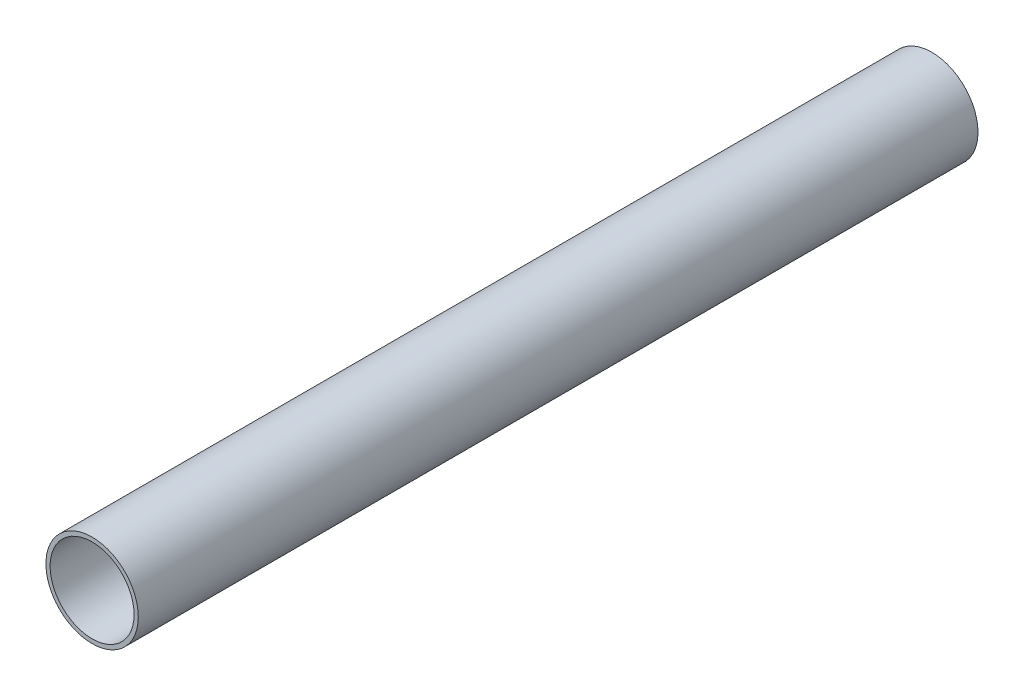
from build123d import *

# Parameters (mm, degrees)
ESQUISSE1_R      = 1.65
ESQUISSE1_R_2    = 1.5
EXTRUSION1_DEPTH = 30


with BuildPart() as part:
    # Esquisse1 → Extrusion1 (new body)
    with BuildSketch(Plane.XY):
        Circle(ESQUISSE1_R)
        Circle(ESQUISSE1_R_2, mode=Mode.SUBTRACT)
    extrude(amount=EXTRUSION1_DEPTH)


solid = part.part
